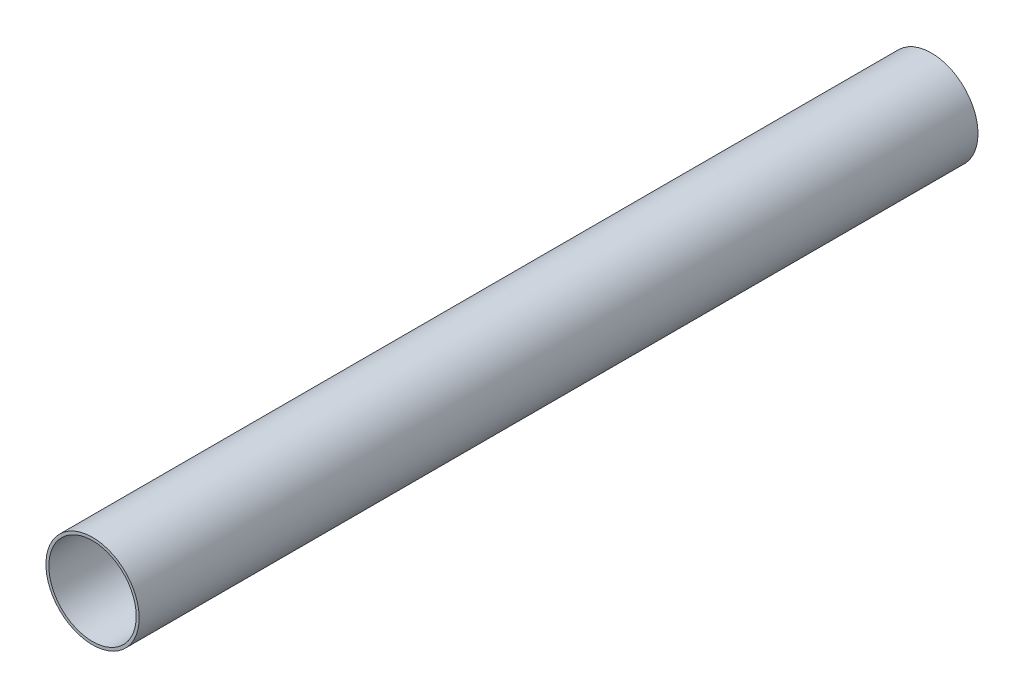
from build123d import *

# Parameters (mm, degrees)
PIPESKETCH_R    = 304.8
PIPESKETCH_R_2  = 285.75
EXTRUSION_DEPTH = 5486.4


with BuildPart() as part:
    # PipeSketch → Extrusion (new body)
    with BuildSketch(Plane.XY):
        Circle(PIPESKETCH_R)
        Circle(PIPESKETCH_R_2, mode=Mode.SUBTRACT)
    extrude(amount=EXTRUSION_DEPTH)


solid = part.part
